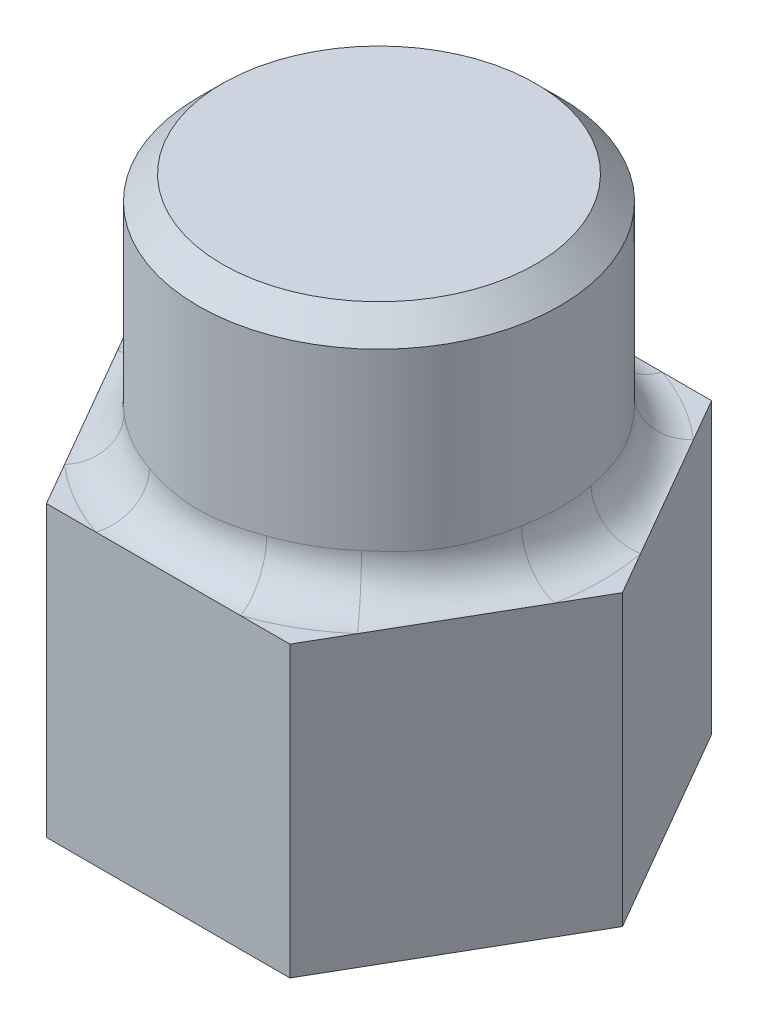
from build123d import *

# Parameters (mm, degrees)
EXTRUDE_1_DEPTH = 4.8
SKETCH_2_R      = 3
EXTRUDE_2_DEPTH = 4
FILLET_4_R      = 0.7
CHAMFER_1_SIZE  = 0.4


with BuildPart() as part:
    # Эскиз1 → Бобышка-Вытянуть1 (new body)
    with BuildSketch(Plane(origin=(0, 0, 0), x_dir=(1, 0, 0), z_dir=(0, 1, 0))):
        Polygon((4.041451884, 0), (2.020725942, 3.5), (-2.020725942, 3.5), (-4.041451884, 0), (-2.020725942, -3.5), (2.020725942, -3.5), align=None)
    extrude(amount=EXTRUDE_1_DEPTH)

    # Эскиз2 → Бобышка-Вытянуть2 (add)
    with BuildSketch(Plane(origin=(0, 4.8, 0), x_dir=(1, 0, 0), z_dir=(0, 1, 0))):
        with Locations(Location((0, 0, 0), (0, 0, 270))):
            Circle(SKETCH_2_R)
    extrude(amount=EXTRUDE_2_DEPTH)

    # Скругление4
    fillet_4_edges = [part.edges().sort_by_distance(p)[0] for p in [
        (0, 4.8, -3),
    ]]
    fillet(fillet_4_edges, radius=FILLET_4_R)

    # Фаска1
    chamfer_1_edges = [part.edges().sort_by_distance(p)[0] for p in [
        (0, 8.8, -3),
    ]]
    chamfer(chamfer_1_edges, length=CHAMFER_1_SIZE)


solid = part.part
